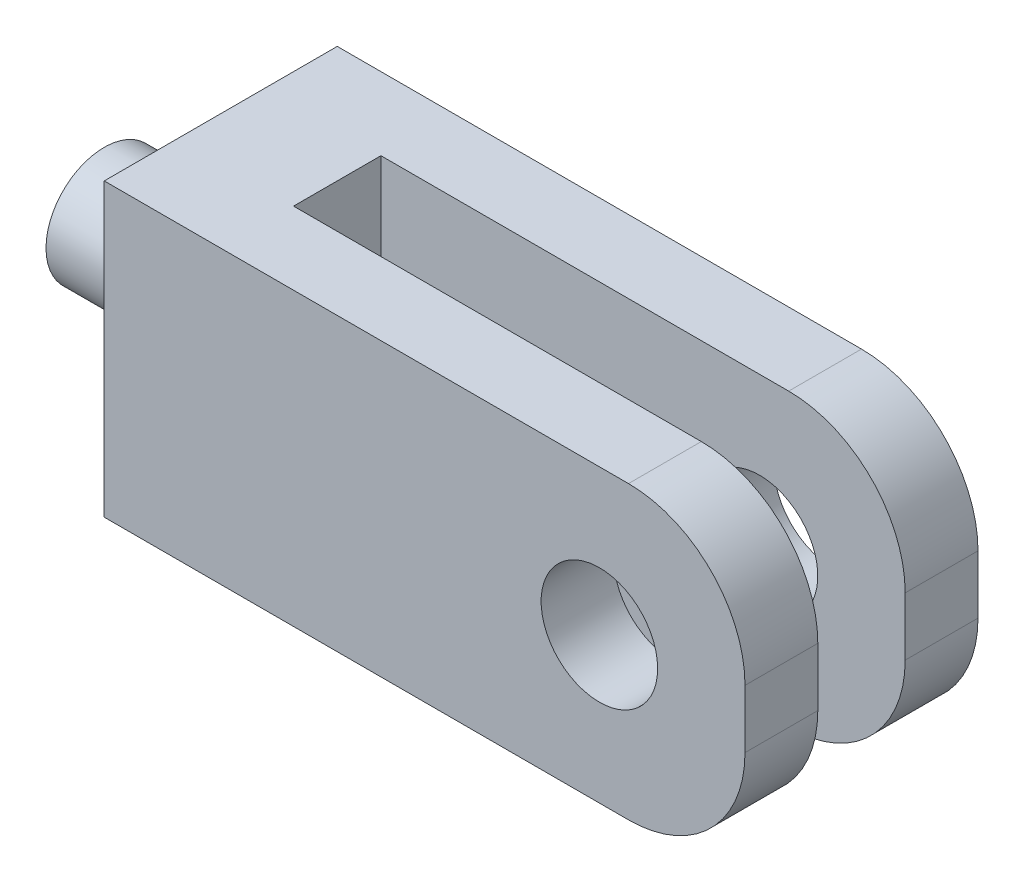
from build123d import *

# Parameters (mm, degrees)
SKETCH1_W           = 110
SKETCH1_H           = 50
BOSS_EXTRUDE1_DEPTH = 40
SKETCH2_W           = 15
SKETCH2_H           = 50
CUT_EXTRUDE1_DEPTH  = 90
FILLET1_R           = 20
SKETCH3_R           = 10
CUT_EXTRUDE2_DEPTH  = 90
SKETCH4_R           = 10
BOSS_EXTRUDE2_DEPTH = 20


with BuildPart() as part:
    # Sketch1 → Boss-Extrude1 (new body)
    with BuildSketch(Plane.XY):
        Rectangle(SKETCH1_W, SKETCH1_H)
    extrude(amount=BOSS_EXTRUDE1_DEPTH)

    # Sketch2 → Cut-Extrude1 (cut)
    with BuildSketch(Plane(origin=(55, 0, 0), x_dir=(0, 0, -1), z_dir=(1, 0, 0))):
        with Locations((-20, 0)):
            Rectangle(SKETCH2_W, SKETCH2_H)
    extrude(amount=-CUT_EXTRUDE1_DEPTH, mode=Mode.SUBTRACT)

    # Fillet1
    fillet1_edges = [part.edges().sort_by_distance(p)[0] for p in [
        (55, -25, 6.25),
        (55, 25, 6.25),
        (55, -25, 33.75),
        (55, 25, 33.75),
    ]]
    fillet(fillet1_edges, radius=FILLET1_R)

    # Sketch3 → Cut-Extrude2 (cut)
    with BuildSketch(Plane.XY.offset(40)):
        with Locations((30, 0)):
            Circle(SKETCH3_R)
    extrude(amount=-CUT_EXTRUDE2_DEPTH, mode=Mode.SUBTRACT)

    # Sketch4 → Boss-Extrude2 (add)
    with BuildSketch(Plane.ZY.offset(55)):
        with Locations((20, 0)):
            Circle(SKETCH4_R)
    extrude(amount=BOSS_EXTRUDE2_DEPTH)


solid = part.part
